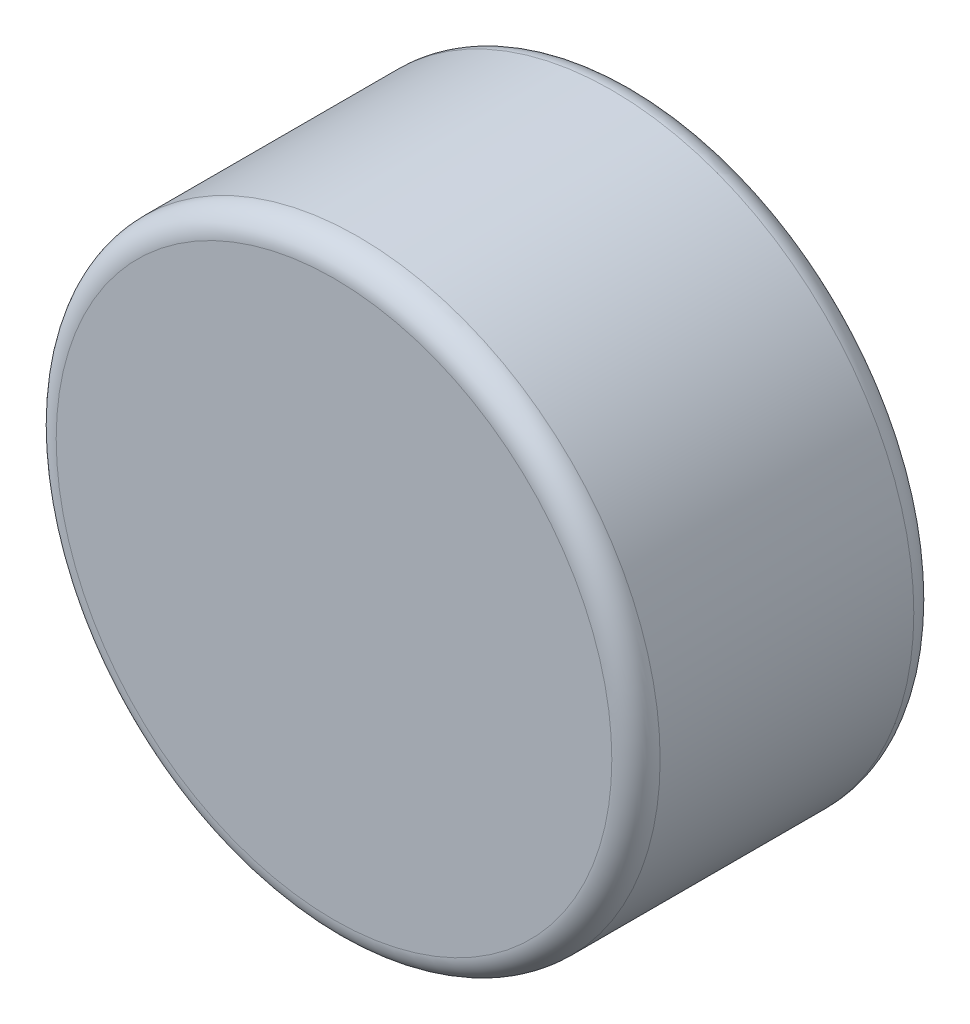
from build123d import *

# Parameters (mm, degrees)
SCHIZZO1_R                   = 2.5
ESTRUSIONE_ESTRUSIONE1_DEPTH = 2.5
RACCORDO1_R                  = 0.2


with BuildPart() as part:
    # Schizzo1 → Estrusione-Estrusione1 (new body)
    with BuildSketch(Plane.XY):
        Circle(SCHIZZO1_R)
    extrude(amount=ESTRUSIONE_ESTRUSIONE1_DEPTH)

    # Raccordo1
    raccordo1_edges = [part.edges().sort_by_distance(p)[0] for p in [
        (-2.5, 0, 0),
        (-2.5, 0, 2.5),
    ]]
    fillet(raccordo1_edges, radius=RACCORDO1_R)


solid = part.part
